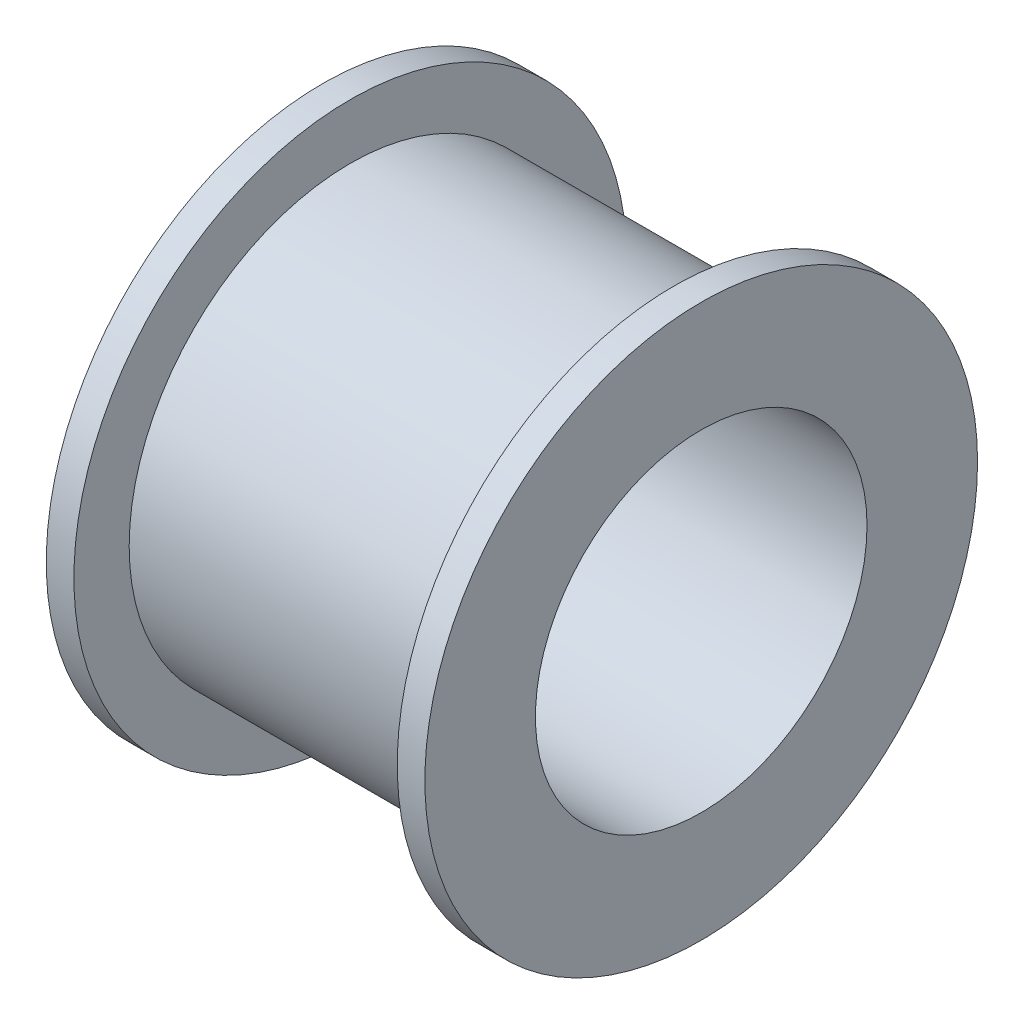
from build123d import *


with BuildPart() as part:
    # Sketch1 → Revolve1 (revolve)
    with BuildSketch(Plane.XY):
        Polygon((0, 100), (0, 60), (68.5, 60), (68.5, 80), (10, 80), (10, 100), align=None)
    revolve1 = revolve(axis=Axis((71.925, 0, 0), (-1, 0, 0)))

    # Mirror1: Revolve1 across plane
    add(revolve1.mirror(Plane(origin=(68.5, 80, 0), x_dir=(0, 0, 1), z_dir=(1, 0, 0))))


solid = part.part
